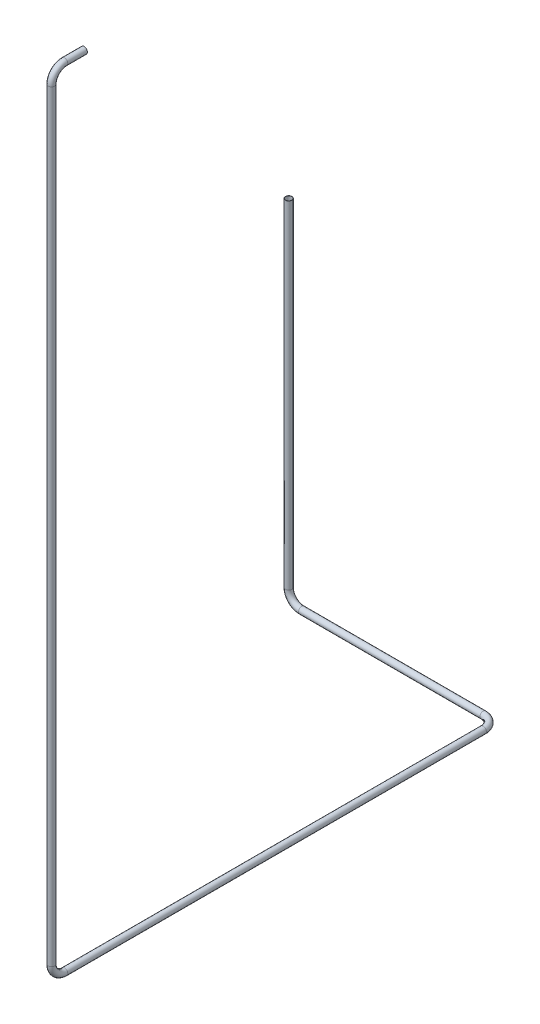
from build123d import *

# Parameters (mm, degrees)
SWEEP_THIN1_PROFILE_R   = 15
SWEEP_THIN1_PROFILE_R_2 = 14


with BuildPart() as part:
    # Sweep-Thin1: sweep along a curve in space
    with BuildLine() as sweep_thin1_path:
        Line((-33126.117683292, -14247.013633934, 43140.470196057), (-33126.117683292, -14247.013633934, 43230.470196057))
        ThreePointArc((-33126.117683292, -14307.013633934, 43290.470196057), (-33126.117683292, -14264.587227063, 43272.896602928), (-33126.117683292, -14247.013633934, 43230.470196057))
        Line((-33126.117683292, -14307.013633934, 43290.470196057), (-33126.117683292, -17802.331772457, 43290.470196057))
        ThreePointArc((-33126.117683292, -17862.331772457, 43230.470196057), (-33126.117683292, -17844.758179328, 43272.896602928), (-33126.117683292, -17802.331772457, 43290.470196057))
        Line((-33126.117683292, -17862.331772457, 43230.470196057), (-33126.117683292, -17862.331772457, 41310.135051864))
        ThreePointArc((-33186.117683292, -17862.331772457, 41250.135051864), (-33143.69127642, -17862.331772457, 41267.708644993), (-33126.117683292, -17862.331772457, 41310.135051864))
        Line((-33186.117683292, -17862.331772457, 41250.135051864), (-34018.284305403, -17862.331772457, 41250.135051864))
        ThreePointArc((-34078.284305403, -17802.331772457, 41250.135051864), (-34060.710712274, -17844.758179328, 41250.135051864), (-34018.284305403, -17862.331772457, 41250.135051864))
        Line((-34078.284305403, -17802.331772457, 41250.135051864), (-34078.284305403, -16256.702563295, 41250.135051864))
    # Sweep-Thin1 profile (on start of the path) → Sweep-Thin1 (sweep)
    with BuildSketch(Plane(origin=(-33126.117683292, -14247.013633934, 43140.470196057), x_dir=(1, 0, 0), z_dir=(0, 0, 1))):
        Circle(SWEEP_THIN1_PROFILE_R)
        Circle(SWEEP_THIN1_PROFILE_R_2, mode=Mode.SUBTRACT)
    sweep(path=sweep_thin1_path.line)


solid = part.part
